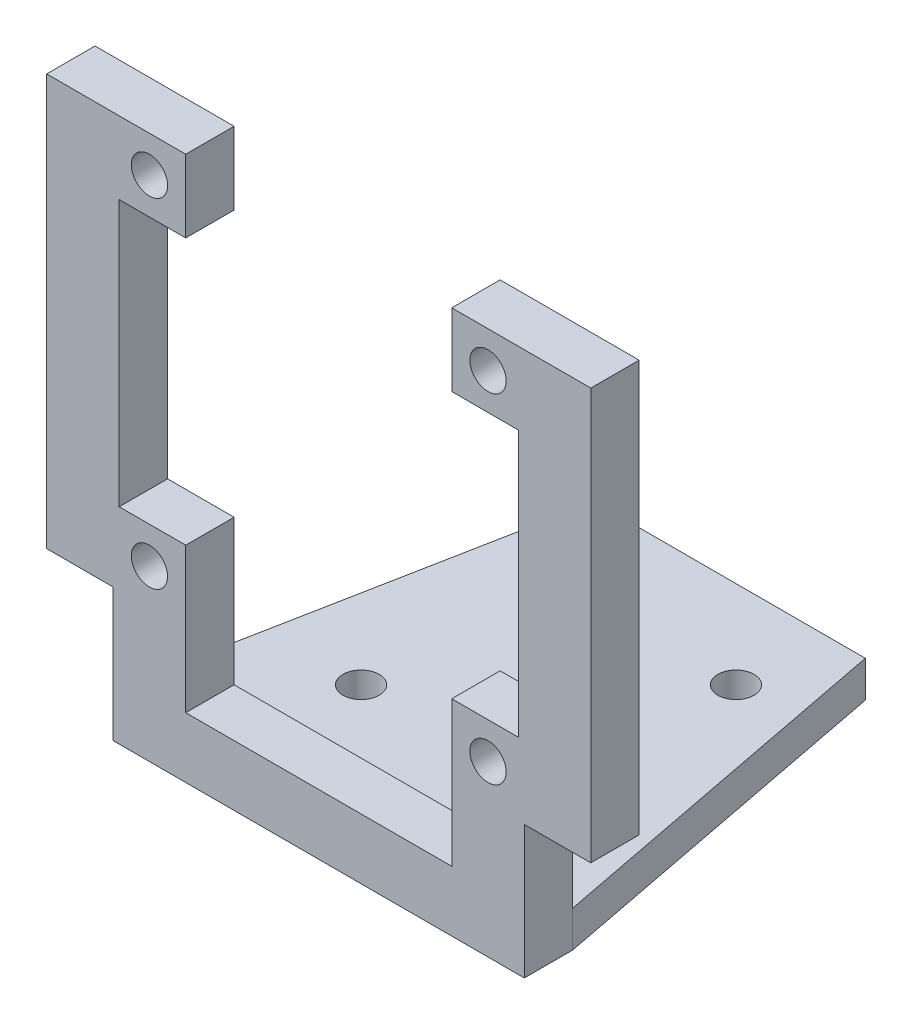
from build123d import *

# Parameters (mm, degrees)
SKETCH1_R             = 1.5
BOSS_EXTRUDE1_DEPTH   = 4
SKETCH2_W             = 34
SKETCH2_H             = 3
BOSS_EXTRUDE2_DEPTH   = 30
F_3_0MM_DOWEL_HOLE1_D = 3
CIRPATTERN1_COUNT     = 4
CUT_EXTRUDE1_DEPTH    = 31
SKETCH7_W             = 5.5
SKETCH7_H             = 34
BOSS_EXTRUDE3_DEPTH   = 4
SKETCH8_W             = 5.5
SKETCH8_H             = 22
CUT_EXTRUDE2_DEPTH    = 32


with BuildPart() as part:
    # Sketch1 → Boss-Extrude1 (new body)
    with BuildSketch(Plane.XY):
        Polygon((11, 17), (17, 17), (17, -28), (-17, -28), (-17, 17), (-11, 17), (-11, -23), (11, -23), align=None)
        with Locations((-14, 14)):
            Circle(SKETCH1_R, mode=Mode.SUBTRACT)
        with Locations((14, 14)):
            Circle(SKETCH1_R, mode=Mode.SUBTRACT)
        with Locations((14, -14)):
            Circle(SKETCH1_R, mode=Mode.SUBTRACT)
        with Locations((-14, -14)):
            Circle(SKETCH1_R, mode=Mode.SUBTRACT)
    extrude(amount=BOSS_EXTRUDE1_DEPTH)

    # Sketch2 → Boss-Extrude2 (add)
    with BuildSketch(Plane(origin=(0, 0, 0), x_dir=(-1, 0, 0), z_dir=(0, 0, -1))):
        with Locations((0, -26.5)):
            Rectangle(SKETCH2_W, SKETCH2_H)
    extrude(amount=BOSS_EXTRUDE2_DEPTH)

    # Ø3.0mm Dowel Hole1 (through all)
    with Locations(Plane(origin=(0, -25, 0), x_dir=(1, 0, 0), z_dir=(0, 1, 0))):
        with Locations((7.75, 22.75)):
            f_3_0mm_dowel_hole1 = Hole(F_3_0MM_DOWEL_HOLE1_D / 2)

    # CirPattern1: Ø3.0mm Dowel Hole1 ×4 about axis
    cirpattern1_axis = Axis((0, 0, -15), (0, 1, 0))
    for i in range(1, CIRPATTERN1_COUNT):
        add(f_3_0mm_dowel_hole1.rotate(cirpattern1_axis, i * 360 / CIRPATTERN1_COUNT), mode=Mode.SUBTRACT)

    # Sketch6 → Cut-Extrude1 (cut)
    with BuildSketch(Plane(origin=(0, -25, 0), x_dir=(1, 0, 0), z_dir=(0, 1, 0))):
        Polygon((17, 0), (11.20263996, 30), (17, 30), align=None)
    cut_extrude1 = extrude(amount=-CUT_EXTRUDE1_DEPTH, mode=Mode.SUBTRACT)

    # Mirror1: Cut-Extrude1 across plane
    add(cut_extrude1.mirror(Plane(origin=(0, 0, 0), x_dir=(0, 0, 1), z_dir=(1, 0, 0))), mode=Mode.SUBTRACT)

    # Sketch7 → Boss-Extrude3 (add)
    with BuildSketch(Plane.XY.offset(4)):
        with Locations((19.75, 0)):
            Rectangle(SKETCH7_W, SKETCH7_H)
    boss_extrude3 = extrude(amount=-BOSS_EXTRUDE3_DEPTH)

    # Sketch8 → Cut-Extrude2 (cut)
    with BuildSketch(Plane.XY.offset(4)):
        with Locations((13.75, 0)):
            Rectangle(SKETCH8_W, SKETCH8_H)
    cut_extrude2 = extrude(amount=-CUT_EXTRUDE2_DEPTH, mode=Mode.SUBTRACT)

    # Mirror2: Boss-Extrude3 across plane
    add(boss_extrude3.mirror(Plane(origin=(0, 0, 0), x_dir=(0, 0, 1), z_dir=(1, 0, 0))))

    # Mirror3: Cut-Extrude2 across plane
    add(cut_extrude2.mirror(Plane(origin=(0, 0, 0), x_dir=(0, 0, 1), z_dir=(1, 0, 0))), mode=Mode.SUBTRACT)


solid = part.part
